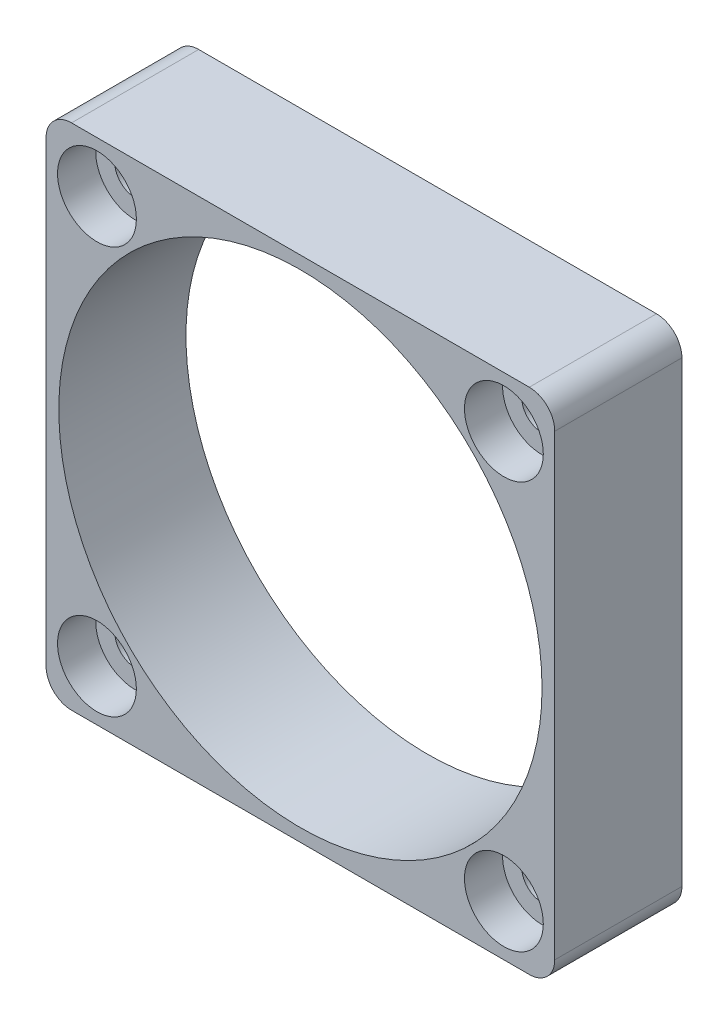
from build123d import *

# Parameters (mm, degrees)
SKETCH1_W           = 40
SKETCH1_H           = 40
BOSS_EXTRUDE1_DEPTH = 10
SKETCH2_R           = 19
SKETCH2_R_2         = 1.6
CUT_EXTRUDE1_DEPTH  = 11
FILLET1_R           = 2
SKETCH3_R           = 3.1
CUT_EXTRUDE2_DEPTH  = 3


with BuildPart() as part:
    # Sketch1 → Boss-Extrude1 (new body)
    with BuildSketch(Plane.XY):
        Rectangle(SKETCH1_W, SKETCH1_H)
    extrude(amount=BOSS_EXTRUDE1_DEPTH)

    # Sketch2 → Cut-Extrude1 (cut, through all)
    with BuildSketch(Plane.XY.offset(10)):
        Circle(SKETCH2_R)
        with Locations((-16, 16)):
            Circle(SKETCH2_R_2)
        with Locations((16, 16)):
            Circle(SKETCH2_R_2)
        with Locations((16, -16)):
            Circle(SKETCH2_R_2)
        with Locations((-16, -16)):
            Circle(SKETCH2_R_2)
    extrude(amount=-CUT_EXTRUDE1_DEPTH, mode=Mode.SUBTRACT)

    # Fillet1
    fillet1_edges = [part.edges().sort_by_distance(p)[0] for p in [
        (20, -20, 5),
        (-20, -20, 5),
        (-20, 20, 5),
        (20, 20, 5),
    ]]
    fillet(fillet1_edges, radius=FILLET1_R)

    # Sketch3 → Cut-Extrude2 (cut)
    with BuildSketch(Plane.XY.offset(10)):
        with Locations((-16, -16)):
            Circle(SKETCH3_R)
        with Locations((16, -16)):
            Circle(SKETCH3_R)
        with Locations((16, 16)):
            Circle(SKETCH3_R)
        with Locations((-16, 16)):
            Circle(SKETCH3_R)
    extrude(amount=-CUT_EXTRUDE2_DEPTH, mode=Mode.SUBTRACT)


solid = part.part
